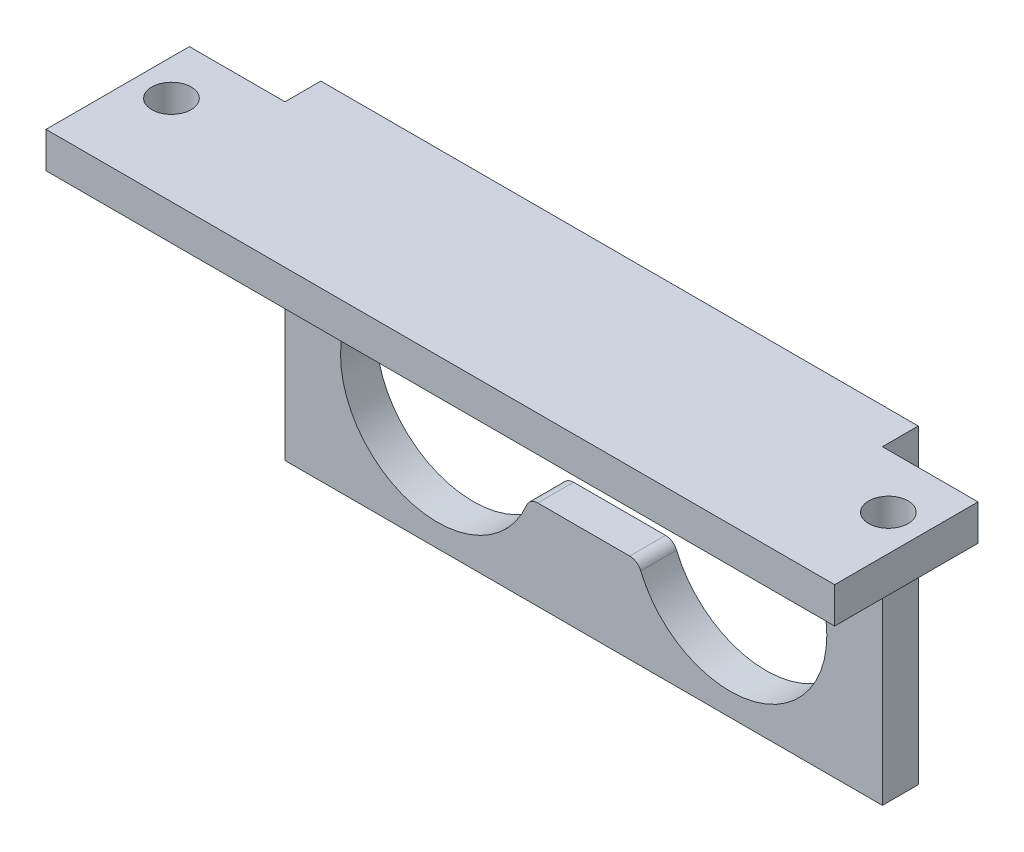
from build123d import *

# Parameters (mm, degrees)
SKETCH_1_W          = 50
SKETCH_1_H          = 20
EXTRUDE_1_DEPTH     = 3
SKETCH_2_W          = 50
SKETCH_2_H          = 15
EXTRUDE_2_DEPTH     = 6
SKETCH_5_W          = 50
SKETCH_5_H          = 12
CUT_EXTRUDE_2_DEPTH = 3
SKETCH_6_W          = 8
SKETCH_6_H          = 12
SKETCH_6_R          = 1.65
EXTRUDE_3_DEPTH     = 3


with BuildPart() as part:
    # 草图1 → 凸台-拉伸1 (new body)
    with BuildSketch(Plane.XY):
        Rectangle(SKETCH_1_W, SKETCH_1_H)
        with BuildLine():
            Line((-3.85, 2.5), (3.85, 2.5))
            ThreePointArc((3.85, 2.5), (4.404700196, 2.667949706), (4.773076923, 3.115384615))
            ThreePointArc((4.773076923, 3.115384615), (20.35, 0), (4.773076923, -3.115384615))
            ThreePointArc((4.773076923, -3.115384615), (4.404700196, -2.667949706), (3.85, -2.5))
            Line((3.85, -2.5), (-3.85, -2.5))
            ThreePointArc((-3.85, -2.5), (-4.404700196, -2.667949706), (-4.773076923, -3.115384615))
            ThreePointArc((-4.773076923, -3.115384615), (-20.35, 0), (-4.773076923, 3.115384615))
            ThreePointArc((-4.773076923, 3.115384615), (-4.404700196, 2.667949706), (-3.85, 2.5))
        make_face(mode=Mode.SUBTRACT)
        with BuildLine():
            Line((3.25, 5.5), (-3.25, 5.5))
            ThreePointArc((-3.25, 5.5), (-5, 7.25), (-3.25, 9))
            Line((-3.25, 9), (3.25, 9))
            ThreePointArc((3.25, 9), (5, 7.25), (3.25, 5.5))
        make_face(mode=Mode.SUBTRACT)
    extrude(amount=EXTRUDE_1_DEPTH)

    # 草图2 → 凸台-拉伸2 (add)
    with BuildSketch(Plane(origin=(0, 10, 0), x_dir=(1, 0, 0), z_dir=(0, 1, 0))):
        with Locations((0, -7.5)):
            Rectangle(SKETCH_2_W, SKETCH_2_H)
    extrude(amount=EXTRUDE_2_DEPTH)

    # 草图5 → 切除-拉伸2 (cut)
    with BuildSketch(Plane.XZ.offset(-10)):
        with Locations((0, 9)):
            Rectangle(SKETCH_5_W, SKETCH_5_H)
    extrude(amount=-CUT_EXTRUDE_2_DEPTH, mode=Mode.SUBTRACT)

    # 草图6 → 凸台-拉伸3 (add)
    with BuildSketch(Plane(origin=(0, 16, 0), x_dir=(1, 0, 0), z_dir=(0, 1, 0))):
        with Locations((29, -9)):
            Rectangle(SKETCH_6_W, SKETCH_6_H)
        with Locations((30, -7.5)):
            Circle(SKETCH_6_R, mode=Mode.SUBTRACT)
        with Locations((-29, -9)):
            Rectangle(SKETCH_6_W, SKETCH_6_H)
        with Locations((-30, -7.5)):
            Circle(SKETCH_6_R, mode=Mode.SUBTRACT)
    extrude(amount=-EXTRUDE_3_DEPTH)


solid = part.part
